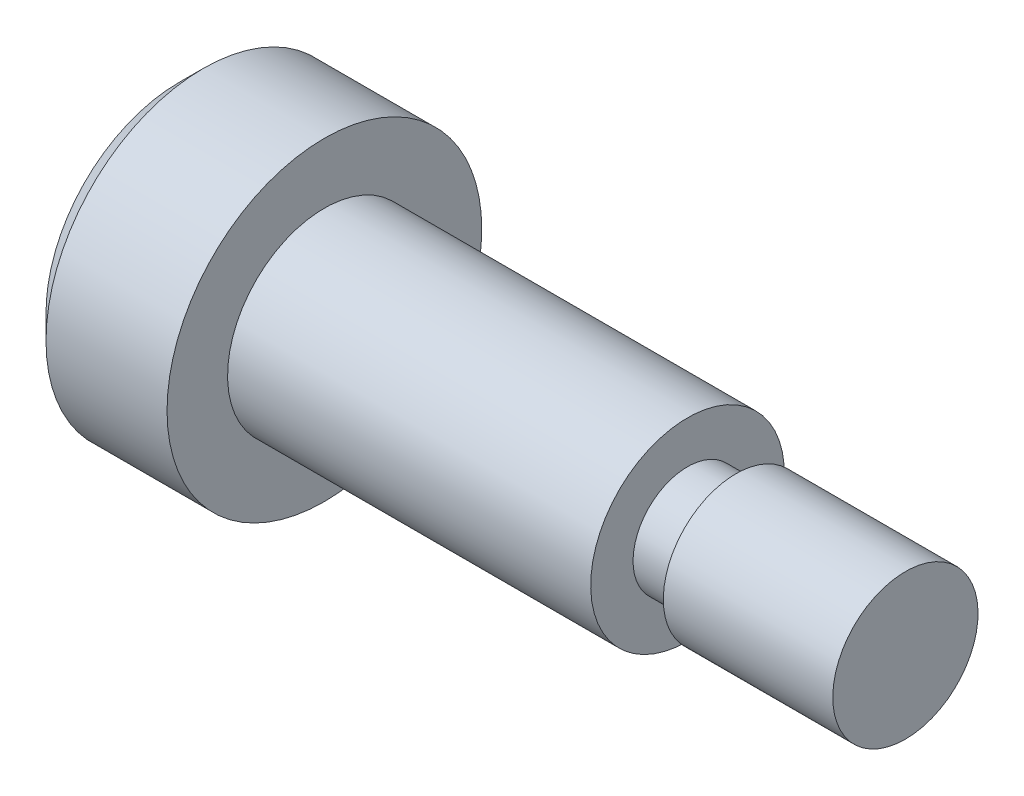
from build123d import *

# Parameters (mm, degrees)
CUT_EXTRUDE1_DEPTH = 3
CHAMFER1_SIZE      = 1


with BuildPart() as part:
    # Sketch1 → Revolve1 (revolve)
    with BuildSketch(Plane.XY):
        Polygon((-6, 0), (-6, 6.5), (0, 6.5), (0, 4), (15, 4), (15, 2.25), (17, 2.25), (17, 3), (24, 3), (24, 0), align=None)
    revolve(axis=Axis((-26.012554328, 0, 0), (1, 0, 0)))

    # Sketch2 → Cut-Extrude1 (cut)
    with BuildSketch(Plane.ZY.offset(6)):
        Polygon((2.886751346, 0), (1.443375673, 2.5), (-1.443375673, 2.5), (-2.886751346, 0), (-1.443375673, -2.5), (1.443375673, -2.5), align=None)
    extrude(amount=-CUT_EXTRUDE1_DEPTH, mode=Mode.SUBTRACT)

    # Chamfer1
    chamfer1_edges = [part.edges().sort_by_distance(p)[0] for p in [
        (-6, -6.5, 0),
    ]]
    chamfer(chamfer1_edges, length=CHAMFER1_SIZE)


solid = part.part
